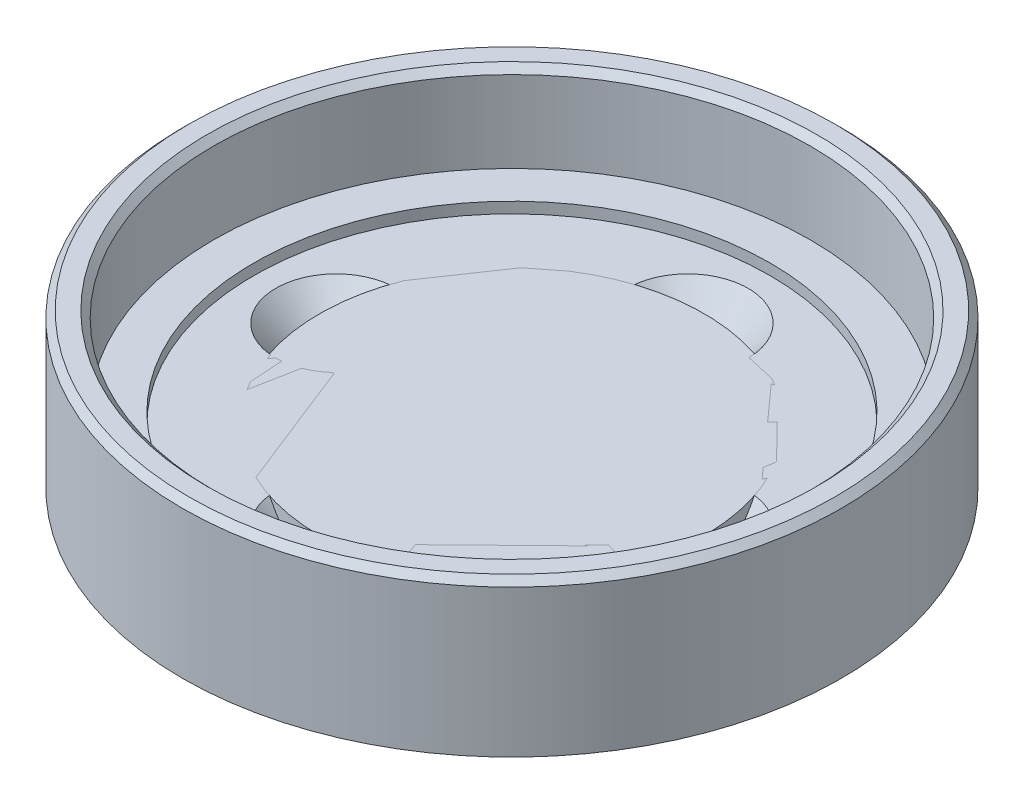
from build123d import *

# Parameters (mm, degrees)
SKETCH1_R                                      = 15
BOSS_EXTRUDE1_DEPTH                            = 6.2
SKETCH2_R                                      = 11.75
CUT_EXTRUDE1_DEPTH                             = 0.5
SKETCH3_R                                      = 15
SKETCH3_R_2                                    = 13.575
BOSS_EXTRUDE2_DEPTH                            = 4
SKETCH4_R                                      = 1.65
CUT_EXTRUDE2_DEPTH                             = 22.96565501
SKETCH6_R                                      = 16.5
SKETCH6_R_2                                    = 1.65
BOSS_EXTRUDE3_DEPTH                            = 1
SKETCH18_R                                     = 2.9
CUT_EXTRUDE10_DEPTH                            = 0.7
CHAMFER2_SIZE                                  = 0.3
SKETCH23_R                                     = 8.75
BOSS_EXTRUDE5_DEPTH                            = 5
SKETCH27_R                                     = 16.5
CUT_EXTRUDE16_DEPTH                            = 10
SKETCH28_R                                     = 1.25
CUT_EXTRUDE17_DEPTH                            = 10
CSK_FOR_M2_5_FLAT_HEAD_MACHINE_SCREW1_AT_COUNT = 2
CSK_FOR_M2_5_FLAT_HEAD_MACHINE_SCREW1_AT_PITCH = 11.313708499
CSK_FOR_M2_5_FLAT_HEAD_MACHINE_SCREW_2_COUNT   = 2
CSK_FOR_M2_5_FLAT_HEAD_MACHINE_SCREW_2_PITCH   = 11.313708499
CSK_FOR_M2_5_FLAT_HEAD_MACHINE_SCREW_3_COUNT   = 2
CSK_FOR_M2_5_FLAT_HEAD_MACHINE_SCREW_3_PITCH   = 16


with BuildPart() as part:
    # Sketch1 → Boss-Extrude1 (new body)
    with BuildSketch(Plane(origin=(0, 0, 0), x_dir=(1, 0, 0), z_dir=(0, 1, 0))):
        Circle(SKETCH1_R)
    extrude(amount=BOSS_EXTRUDE1_DEPTH)

    # Sketch2 → Cut-Extrude1 (cut)
    with BuildSketch(Plane(origin=(0, 6.2, 0), x_dir=(1, 0, 0), z_dir=(0, 1, 0))):
        Circle(SKETCH2_R)
    extrude(amount=-CUT_EXTRUDE1_DEPTH, mode=Mode.SUBTRACT)

    # Sketch3 → Boss-Extrude2 (add)
    with BuildSketch(Plane(origin=(0, 6.2, 0), x_dir=(1, 0, 0), z_dir=(0, 1, 0))):
        Circle(SKETCH3_R)
        Circle(SKETCH3_R_2, mode=Mode.SUBTRACT)
    extrude(amount=BOSS_EXTRUDE2_DEPTH)

    # Sketch4 → Cut-Extrude2 (cut, through all)
    with BuildSketch(Plane(origin=(0, 5.7, 0), x_dir=(1, 0, 0), z_dir=(0, 1, 0))):
        Circle(SKETCH4_R)
    extrude(amount=-CUT_EXTRUDE2_DEPTH, mode=Mode.SUBTRACT)

    # Sketch6 → Boss-Extrude3 (add)
    with BuildSketch(Plane.XZ):
        Circle(SKETCH6_R)
        Circle(SKETCH6_R_2, mode=Mode.SUBTRACT)
    extrude(amount=BOSS_EXTRUDE3_DEPTH)

    # Sketch18 → Cut-Extrude10 (cut)
    with BuildSketch(Plane(origin=(0, 5.7, 0), x_dir=(1, 0, 0), z_dir=(0, 1, 0))):
        Circle(SKETCH18_R)
    extrude(amount=-CUT_EXTRUDE10_DEPTH, mode=Mode.SUBTRACT)

    # Chamfer2
    chamfer2_edges = [part.edges().sort_by_distance(p)[0] for p in [
        (-13.575, 10.2, 0),
        (-15, 10.2, 0),
    ]]
    chamfer(chamfer2_edges, length=CHAMFER2_SIZE)

    # Sketch27 → Cut-Extrude16 (cut)
    with BuildSketch(Plane(origin=(0, 3.2, 0), x_dir=(1, 0, 0), z_dir=(0, 1, 0))):
        Circle(SKETCH27_R)
    extrude(amount=-CUT_EXTRUDE16_DEPTH, mode=Mode.SUBTRACT)

    # Sketch28 → Cut-Extrude17 (cut)
    with BuildSketch(Plane(origin=(0, 5.7, 0), x_dir=(1, 0, 0), z_dir=(0, 1, 0))):
        with Locations((0, 8)):
            Circle(SKETCH28_R)
        with Locations((8, 0)):
            Circle(SKETCH28_R)
        with Locations((0, -8)):
            Circle(SKETCH28_R)
        with Locations((-8, 0)):
            Circle(SKETCH28_R)
    extrude(amount=-CUT_EXTRUDE17_DEPTH, mode=Mode.SUBTRACT)

    # Sketch30 → CSK for M2.5 Flat Head Machine Screw1 (revolve, cut)
    with BuildSketch(Plane(origin=(0, 5.7, -8), x_dir=(0, 0, 1), z_dir=(1, 0, 0))):
        Polygon((0, 0), (0, 5.841204867), (1.4, 5), (1.4, 1.35), (2.75, 0), align=None)
    csk_for_m2_5_flat_head_machine_screw1 = revolve(axis=Axis((0, 12.05, -8), (0, -1, 0)), mode=Mode.SUBTRACT)

    # CSK for M2.5 Flat Head Machine Screw1 at: CSK for M2.5 Flat Head Machine Screw1 ×2
    with Locations(*[Vector(-0.7071067811865276, 0, 0.7071067811865676) * (i * CSK_FOR_M2_5_FLAT_HEAD_MACHINE_SCREW1_AT_PITCH) for i in range(1, CSK_FOR_M2_5_FLAT_HEAD_MACHINE_SCREW1_AT_COUNT)]):
        add(csk_for_m2_5_flat_head_machine_screw1, mode=Mode.SUBTRACT)

    # CSK for M2.5 Flat Head Machine Screw 2: CSK for M2.5 Flat Head Machine Screw1 ×2
    with Locations(*[Vector(0.7071067811865676, 0, 0.7071067811865276) * (i * CSK_FOR_M2_5_FLAT_HEAD_MACHINE_SCREW_2_PITCH) for i in range(1, CSK_FOR_M2_5_FLAT_HEAD_MACHINE_SCREW_2_COUNT)]):
        add(csk_for_m2_5_flat_head_machine_screw1, mode=Mode.SUBTRACT)

    # CSK for M2.5 Flat Head Machine Screw 3: CSK for M2.5 Flat Head Machine Screw1 ×2
    with Locations(*[(0, 0, i * CSK_FOR_M2_5_FLAT_HEAD_MACHINE_SCREW_3_PITCH) for i in range(1, CSK_FOR_M2_5_FLAT_HEAD_MACHINE_SCREW_3_COUNT)]):
        add(csk_for_m2_5_flat_head_machine_screw1, mode=Mode.SUBTRACT)


with BuildPart() as body_2:
    # Sketch23 → Boss-Extrude5 (new body)
    with BuildSketch(Plane(origin=(0, 5.7, 0), x_dir=(1, 0, 0), z_dir=(0, 1, 0))):
        Circle(SKETCH23_R)
    extrude(amount=-BOSS_EXTRUDE5_DEPTH)


solid = Compound([part.part, body_2.part])
